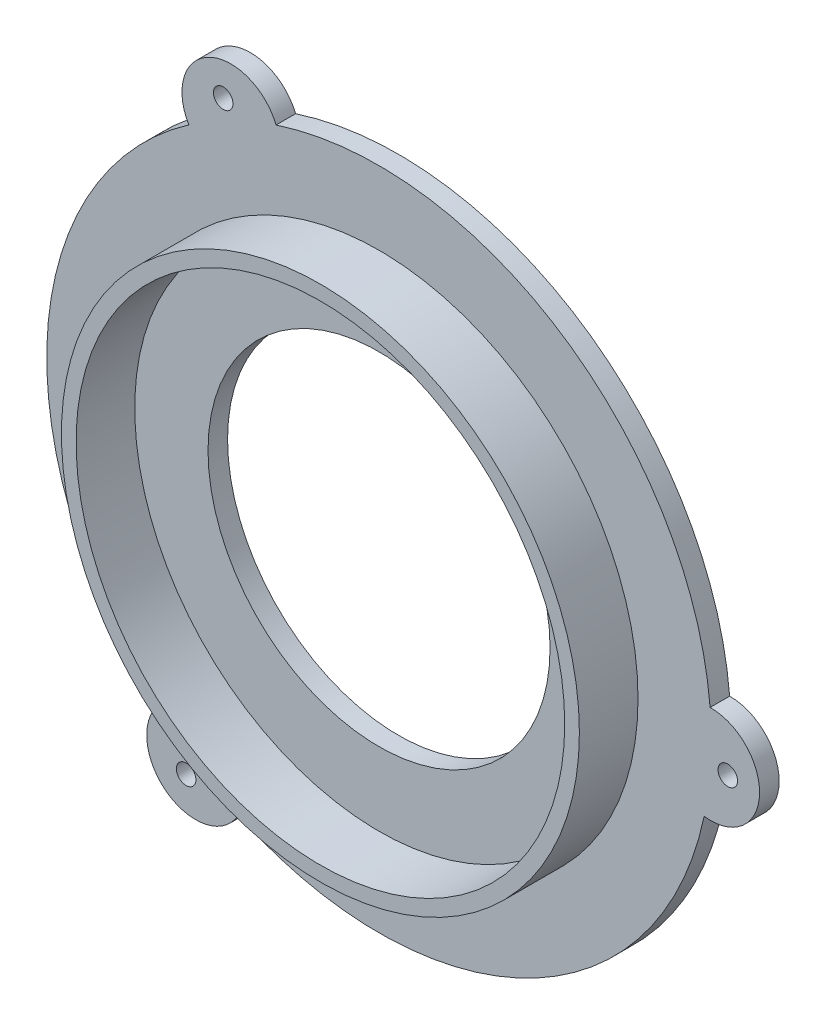
from build123d import *

# Parameters (mm, degrees)
SKETCH1_R           = 1
BOSS_EXTRUDE1_DEPTH = 2
SKETCH2_R           = 26.5
SKETCH2_R_2         = 25
BOSS_EXTRUDE2_DEPTH = 6
SKETCH3_R           = 17.5
CUT_EXTRUDE1_DEPTH  = 6


with BuildPart() as part:
    # Sketch1 → Boss-Extrude1 (new body)
    with BuildSketch(Plane.XY):
        with BuildLine():
            ThreePointArc((-19.463908256, 27.877522763), (-33.936185412, 2.082143047), (-22.725920861, -25.288980229))
            ThreePointArc((-22.725920861, -25.288980229), (-21.53176405, -32.517428202), (-14.410688779, -30.795000388))
            ThreePointArc((-14.410688779, -30.795000388), (15.164903933, -30.430670198), (33.263859745, -7.036734675))
            ThreePointArc((33.263859745, -7.036734675), (38.926800914, -2.388340554), (33.874597035, 2.917477625))
            ThreePointArc((33.874597035, 2.917477625), (18.771281479, 28.348527151), (-10.537938884, 32.325714904))
            ThreePointArc((-10.537938884, 32.325714904), (-17.395036864, 34.905768757), (-19.463908256, 27.877522763))
        make_face()
        with Locations((35.682900838, -2.189312175)):
            Circle(SKETCH1_R, mode=Mode.SUBTRACT)
        with Locations((-19.737450379, -29.807642519)):
            Circle(SKETCH1_R, mode=Mode.SUBTRACT)
        with Locations((-15.945450459, 31.996954694)):
            Circle(SKETCH1_R, mode=Mode.SUBTRACT)
    extrude(amount=BOSS_EXTRUDE1_DEPTH)

    # Sketch2 → Boss-Extrude2 (add)
    with BuildSketch(Plane.XY.offset(2)):
        Circle(SKETCH2_R)
        Circle(SKETCH2_R_2, mode=Mode.SUBTRACT)
    extrude(amount=BOSS_EXTRUDE2_DEPTH)

    # Sketch3 → Cut-Extrude1 (cut)
    with BuildSketch(Plane.XY.offset(2)):
        Circle(SKETCH3_R)
    extrude(amount=-CUT_EXTRUDE1_DEPTH, mode=Mode.SUBTRACT)


solid = part.part
